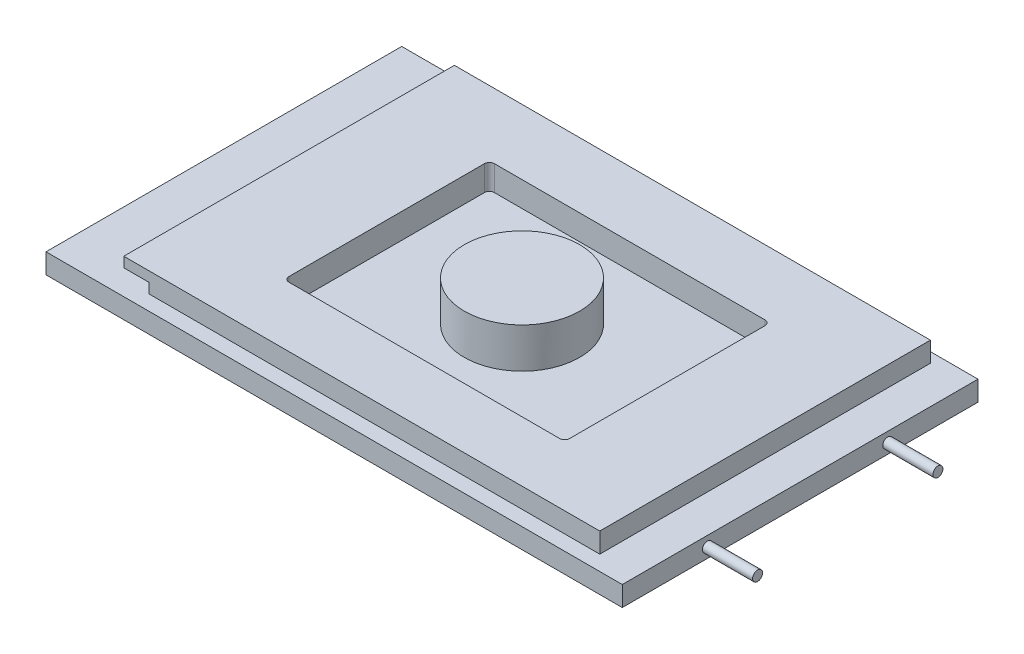
from build123d import *

# Parameters (mm, degrees)
SKETCH1_W           = 115.0112
SKETCH1_H           = 70.993
BOSS_EXTRUDE1_DEPTH = 3.9878
SKETCH2_W           = 89.9922
SKETCH2_H           = 65.9892
BOSS_EXTRUDE2_DEPTH = 1.99898
BOSS_EXTRUDE3_DEPTH = 65.9892
CUT_EXTRUDE1_DEPTH  = 5.0038
SKETCH5_R           = 11.5062
BOSS_EXTRUDE4_DEPTH = 8.001
SKETCH6_R           = 0.99949
BOSS_EXTRUDE5_DEPTH = 10.0076


with BuildPart() as part:
    # Sketch1 → Boss-Extrude1 (new body)
    with BuildSketch(Plane(origin=(0, 0, 0), x_dir=(1, 0, 0), z_dir=(0, 1, 0))):
        with Locations((57.5056, 35.4965)):
            Rectangle(SKETCH1_W, SKETCH1_H)
    extrude(amount=BOSS_EXTRUDE1_DEPTH)

    # Sketch2 → Boss-Extrude2 (add)
    with BuildSketch(Plane(origin=(0, 3.9878, 0), x_dir=(1, 0, 0), z_dir=(0, 1, 0))):
        with Locations((62.5221, 35.9918)):
            Rectangle(SKETCH2_W, SKETCH2_H)
    extrude(amount=BOSS_EXTRUDE2_DEPTH)

    # Sketch3 → Boss-Extrude3 (add)
    with BuildSketch(Plane.XY.offset(-2.9972)):
        Polygon((17.526, 5.98678), (12.5222, 5.98678), (12.5222, 7.98576), (107.5182, 7.98576), (107.5182, 5.98678), align=None)
    extrude(amount=-BOSS_EXTRUDE3_DEPTH)

    # Sketch4 → Cut-Extrude1 (cut)
    with BuildSketch(Plane(origin=(0, 7.98576, 0), x_dir=(1, 0, 0), z_dir=(0, 1, 0))):
        with BuildLine():
            Line((33.5026, 14.986), (87.5284, 14.986))
            ThreePointArc((87.5284, 14.986), (88.228859977, 15.276140023), (88.519, 15.9766))
            Line((88.519, 15.9766), (88.519, 54.991))
            ThreePointArc((88.519, 54.991), (88.228859977, 55.691459977), (87.5284, 55.9816))
            Line((87.5284, 55.9816), (33.5026, 55.9816))
            ThreePointArc((33.5026, 55.9816), (32.802140023, 55.691459977), (32.512, 54.991))
            Line((32.512, 54.991), (32.512, 15.9766))
            ThreePointArc((32.512, 15.9766), (32.802140023, 15.276140023), (33.5026, 14.986))
        make_face()
    extrude(amount=-CUT_EXTRUDE1_DEPTH, mode=Mode.SUBTRACT)

    # Sketch5 → Boss-Extrude4 (add)
    with BuildSketch(Plane(origin=(0, 2.98196, 0), x_dir=(1, 0, 0), z_dir=(0, 1, 0))):
        with Locations((59.0042, 35.9918)):
            Circle(SKETCH5_R)
    extrude(amount=BOSS_EXTRUDE4_DEPTH)

    # Sketch6 → Boss-Extrude5 (add)
    with BuildSketch(Plane(origin=(115.0112, 0, 0), x_dir=(0, 0, -1), z_dir=(1, 0, 0))):
        with Locations((16.9926, 1.99898)):
            Circle(SKETCH6_R)
        with Locations((52.9844, 1.99898)):
            Circle(SKETCH6_R)
    extrude(amount=BOSS_EXTRUDE5_DEPTH)


solid = part.part
